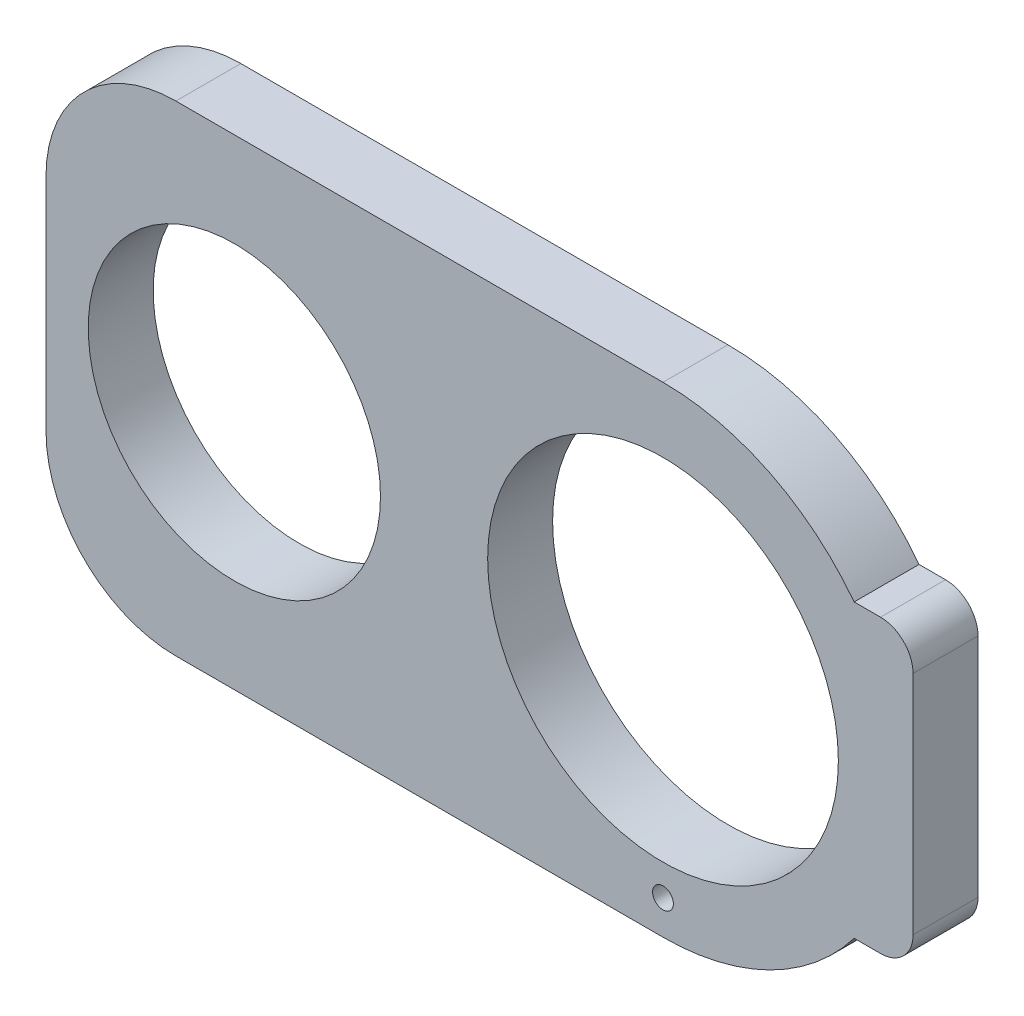
from build123d import *

# Parameters (mm, degrees)
SKETCH1_R           = 27
SKETCH1_R_2         = 22.5
BOSS_EXTRUDE1_DEPTH = 10
SKETCH2_R           = 1.6
CUT_EXTRUDE1_DEPTH  = 11


with BuildPart() as part:
    # Sketch1 → Boss-Extrude1 (new body)
    with BuildSketch(Plane.XY):
        with BuildLine():
            Line((-48.092977135, -207.645932851), (-123.092977135, -207.645932851))
            ThreePointArc((-123.092977135, -207.645932851), (-137.235112759, -201.788068475), (-143.092977135, -187.645932851))
            Line((-143.092977135, -187.645932851), (-143.092977135, -153.645932851))
            ThreePointArc((-143.092977135, -153.645932851), (-137.235112759, -139.503797227), (-123.092977135, -133.645932851))
            Line((-123.092977135, -133.645932851), (-48.092977135, -133.645932851))
            ThreePointArc((-48.092977135, -133.645932851), (-31.673163065, -137.488886754), (-18.664191619, -148.219462263))
            Line((-18.664191619, -148.219462263), (-14.592977135, -148.219462263))
            ThreePointArc((-14.592977135, -148.219462263), (-11.05744323, -149.683928357), (-9.592977135, -153.219462263))
            Line((-9.592977135, -153.219462263), (-9.592977135, -188.072403439))
            ThreePointArc((-9.592977135, -188.072403439), (-11.05744323, -191.607937345), (-14.592977135, -193.072403439))
            Line((-14.592977135, -193.072403439), (-18.664191619, -193.072403439))
            ThreePointArc((-18.664191619, -193.072403439), (-31.673163065, -203.802978948), (-48.092977135, -207.645932851))
        make_face()
        with Locations((-48.092977135, -170.645932851)):
            Circle(SKETCH1_R, mode=Mode.SUBTRACT)
        with Locations((-114.092977135, -170.645932851)):
            Circle(SKETCH1_R_2, mode=Mode.SUBTRACT)
    extrude(amount=-BOSS_EXTRUDE1_DEPTH)

    # Sketch2 → Cut-Extrude1 (cut, through all)
    with BuildSketch(Plane.XY):
        with Locations((-48.092977135, -202.395935058)):
            Circle(SKETCH2_R)
    extrude(amount=-CUT_EXTRUDE1_DEPTH, mode=Mode.SUBTRACT)


solid = part.part
